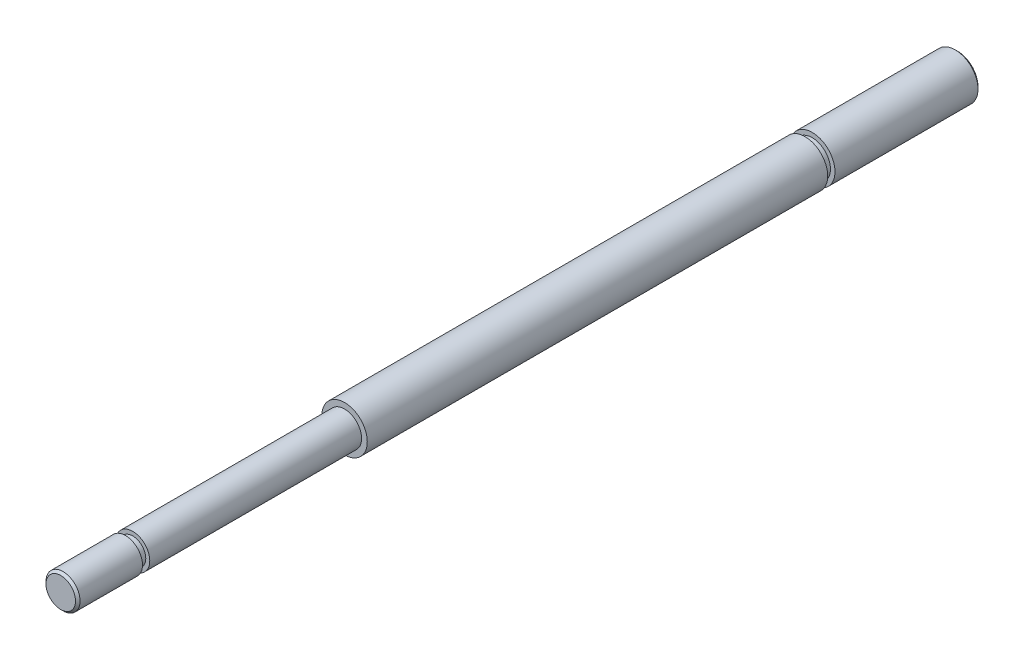
from build123d import *

# Parameters (mm, degrees)
ESQUISSE1_R          = 2
BASE_EXTRUSION_DEPTH = 54
ESQUISSE2_R          = 1.5
BOSS_EXTRU_1_DEPTH   = 25
CHANFREIN1_SIZE      = 0.2
ESQUISSE3_W          = 0.64
ESQUISSE3_H          = 2.403474903
ESQUISSE3_H_2        = 2.734022734


with BuildPart() as part:
    # Esquisse1 → Base-Extrusion (new body)
    with BuildSketch(Plane.XY):
        Circle(ESQUISSE1_R)
    extrude(amount=BASE_EXTRUSION_DEPTH)

    # Esquisse2 → Boss.-Extru.1 (add)
    with BuildSketch(Plane.XY.offset(54)):
        Circle(ESQUISSE2_R)
    extrude(amount=BOSS_EXTRU_1_DEPTH)

    # Chanfrein1
    chanfrein1_edges = [part.edges().sort_by_distance(p)[0] for p in [
        (-2, 0, 0),
        (-1.5, 0, 79),
    ]]
    chamfer(chanfrein1_edges, length=CHANFREIN1_SIZE)

    # Esquisse3 → Enlèvement de matière-Révolution1 (revolve, cut)
    with BuildSketch(Plane(origin=(0, 0, 0), x_dir=(0, 0, -1), z_dir=(1, 0, 0))):
        with Locations((-13.12, 2.801737452)):
            Rectangle(ESQUISSE3_W, ESQUISSE3_H)
        with Locations((-72.98, 2.517011367)):
            Rectangle(ESQUISSE3_W, ESQUISSE3_H_2)
    revolve(axis=Axis((0, 0, 0), (0, 0, -1)), mode=Mode.SUBTRACT)


solid = part.part
